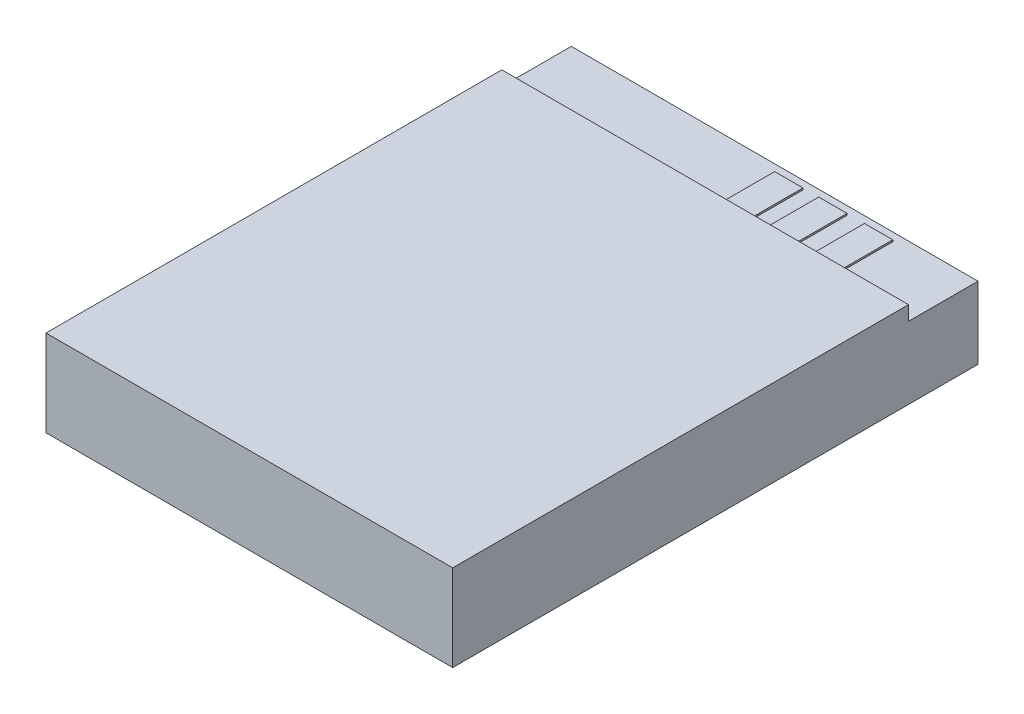
from build123d import *

# Parameters (mm, degrees)
SKETCH_1_W          = 24
SKETCH_1_H          = 31
EXTRUDE_1_DEPTH     = 5.1
SKETCH_2_W          = 24
SKETCH_2_H          = 4.1
CUT_EXTRUDE_1_DEPTH = 0.85
SKETCH_3_W          = 1.67
SKETCH_3_H          = 3
EXTRUDE_2_DEPTH     = 0.1


with BuildPart() as part:
    # Эскиз1 → Бобышка-Вытянуть1 (new body)
    with BuildSketch(Plane(origin=(0, 0, 0), x_dir=(1, 0, 0), z_dir=(0, 1, 0))):
        Rectangle(SKETCH_1_W, SKETCH_1_H)
    extrude(amount=EXTRUDE_1_DEPTH)

    # Эскиз2 → Вырез-Вытянуть1 (cut)
    with BuildSketch(Plane(origin=(0, 5.1, 0), x_dir=(1, 0, 0), z_dir=(0, 1, 0))):
        with Locations((0, 13.45)):
            Rectangle(SKETCH_2_W, SKETCH_2_H)
    extrude(amount=-CUT_EXTRUDE_1_DEPTH, mode=Mode.SUBTRACT)

    # Эскиз3 → Бобышка-Вытянуть2 (add)
    with BuildSketch(Plane(origin=(0, 4.25, 0), x_dir=(1, 0, 0), z_dir=(0, 1, 0))):
        with Locations((1.335, 13.5)):
            Rectangle(SKETCH_3_W, SKETCH_3_H)
        with Locations((3.935, 13.5)):
            Rectangle(SKETCH_3_W, SKETCH_3_H)
        with Locations((6.635, 13.5)):
            Rectangle(SKETCH_3_W, SKETCH_3_H)
    extrude(amount=EXTRUDE_2_DEPTH)


solid = part.part
